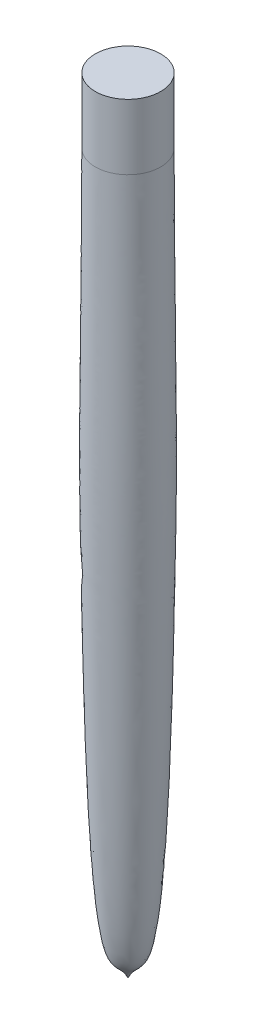
from build123d import *


with BuildPart() as part:
    # Sketch1 → Revolve1 (revolve)
    with BuildSketch(Plane.XY):
        with BuildLine():
            Line((0, 0), (0, -152.4))
            add(Edge.make_bspline(
                [(0, -152.4), (-1.181412375, -149.801170135), (-5.114246261, -152.212684002), (-7.180755218, -54.991267517), (-6.537691989, -63.026029267), (-6.35, -12.7)],
                knots=[0, 0, 0, 0, 0.121075821, 0.416785144, 1, 1, 1, 1], degree=3))
            Line((-6.35, -12.7), (-6.35, 0))
            Line((-6.35, 0), (0, 0))
        make_face()
    revolve(axis=Axis((0, 0, 0), (0, -1, 0)))


solid = part.part
